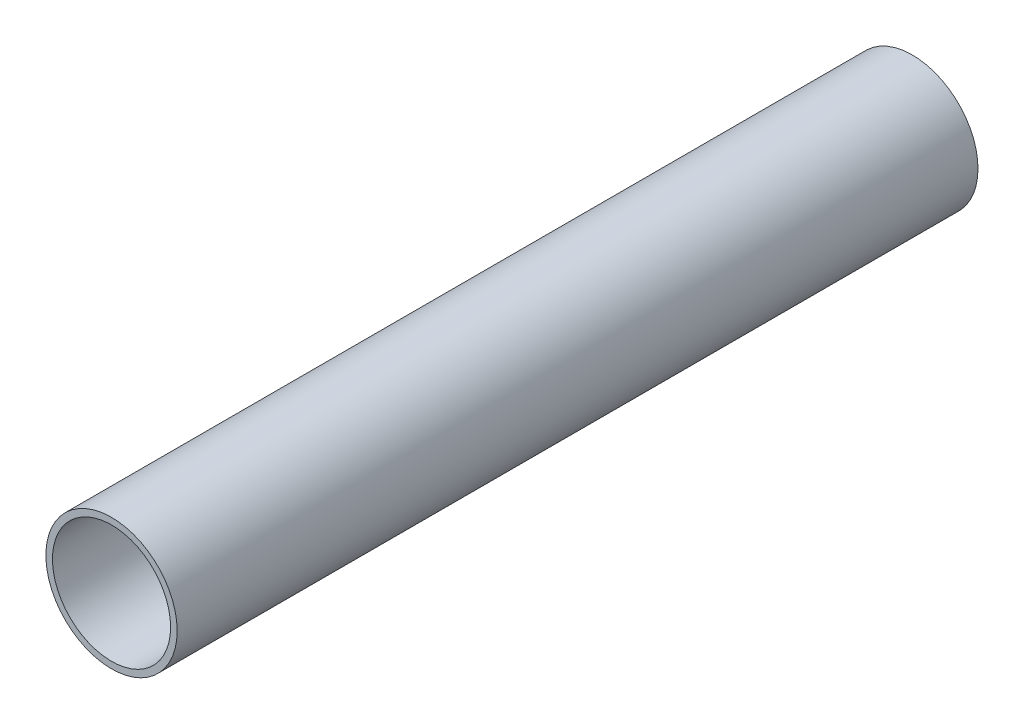
from build123d import *

# Parameters (mm, degrees)
SKETCH3_R           = 10
SKETCH3_R_2         = 9
EXTRUDE_THIN2_DEPTH = 122


with BuildPart() as part:
    # Sketch3 → Extrude-Thin2 (new body)
    with BuildSketch(Plane.XY):
        Circle(SKETCH3_R)
        Circle(SKETCH3_R_2, mode=Mode.SUBTRACT)
    extrude(amount=EXTRUDE_THIN2_DEPTH)


solid = part.part
